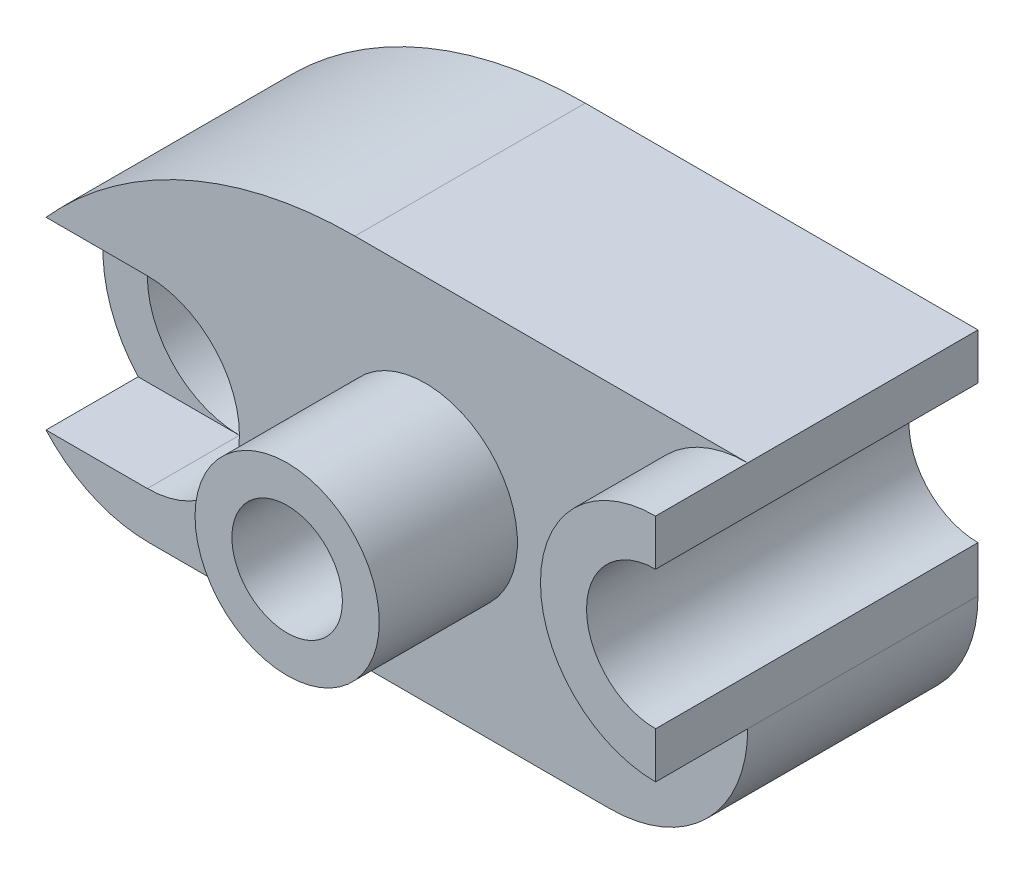
from build123d import *

# Parameters (mm, degrees)
SKETCH1_W           = 160
SKETCH1_H           = 80
BOSS_EXTRUDE1_DEPTH = 90
CUT_EXTRUDE1_DEPTH  = 90
CUT_EXTRUDE2_DEPTH  = 90
SKETCH4_W           = 10
SKETCH4_H           = 15
CUT_EXTRUDE3_DEPTH  = 215
CUT_EXTRUDE4_DEPTH  = 10
CUT_EXTRUDE6_DEPTH  = 263
SKETCH7_W           = 160
SKETCH7_H           = 80
CUT_EXTRUDE7_DEPTH  = 263
SKETCH8_R           = 20
BOSS_EXTRUDE2_DEPTH = 30
SKETCH9_R           = 11
CUT_EXTRUDE8_DEPTH  = 117
BOSS_EXTRUDE3_DEPTH = 20
CUT_EXTRUDE9_DEPTH  = 20
SKETCH12_R          = 20
CUT_EXTRUDE10_DEPTH = 40
SKETCH13_R          = 10
CUT_EXTRUDE11_DEPTH = 40
SKETCH14_R          = 12
CUT_EXTRUDE12_DEPTH = 114


with BuildPart() as part:
    # Sketch1 → Boss-Extrude1 (new body)
    with BuildSketch(Plane.XY):
        with Locations((80, 40)):
            Rectangle(SKETCH1_W, SKETCH1_H)
    extrude(amount=BOSS_EXTRUDE1_DEPTH)

    # Sketch2 → Cut-Extrude1 (cut)
    with BuildSketch(Plane.XY.offset(90)):
        with BuildLine():
            ThreePointArc((160, 70), (145, 55), (160, 40))
            Line((160, 40), (160, 70))
        make_face()
        with BuildLine():
            ThreePointArc((160, 30), (151.213203436, 8.786796564), (130, 0))
            Line((130, 0), (160, 0))
            Line((160, 0), (160, 30))
        make_face()
    extrude(amount=-CUT_EXTRUDE1_DEPTH, mode=Mode.SUBTRACT)

    # Sketch3 → Cut-Extrude2 (cut)
    with BuildSketch(Plane.XY.offset(90)):
        with BuildLine():
            Line((0, 30), (0, 0))
            Line((0, 0), (30, 0))
            ThreePointArc((30, 0), (8.786796564, 8.786796564), (0, 30))
        make_face()
    extrude(amount=-CUT_EXTRUDE2_DEPTH, mode=Mode.SUBTRACT)

    # Sketch4 → Cut-Extrude3 (cut)
    with BuildSketch(Plane.ZY):
        with Locations((5, 72.5)):
            Rectangle(SKETCH4_W, SKETCH4_H)
        with Locations((5, 7.5)):
            Rectangle(SKETCH4_W, SKETCH4_H)
    extrude(amount=-CUT_EXTRUDE3_DEPTH, mode=Mode.SUBTRACT)

    # Sketch5 → Cut-Extrude4 (cut)
    with BuildSketch(Plane(origin=(0, 0, 0), x_dir=(-1, 0, 0), z_dir=(0, 0, -1))):
        with BuildLine():
            ThreePointArc((-90, 15), (-115, 40), (-90, 65))
            Line((-90, 65), (-148.819660113, 65))
            ThreePointArc((-148.819660113, 65), (-146.306936062, 48.876275643), (-160, 40))
            Line((-160, 40), (-160, 30))
            ThreePointArc((-160, 30), (-158.977774789, 22.235428647), (-155.980762114, 15))
            Line((-155.980762114, 15), (-90, 15))
        make_face()
        with BuildLine():
            Line((0, 65), (-90, 65))
            ThreePointArc((-90, 65), (-72.32233047, 57.67766953), (-65, 40))
            ThreePointArc((-65, 40), (-72.32233047, 22.32233047), (-90, 15))
            Line((-90, 15), (-4.019237886, 15))
            ThreePointArc((-4.019237886, 15), (-1.022225211, 22.235428647), (0, 30))
            Line((0, 30), (0, 65))
        make_face()
    extrude(amount=-CUT_EXTRUDE4_DEPTH, mode=Mode.SUBTRACT)

    # Sketch6 → Cut-Extrude6 (cut)
    with BuildSketch(Plane.XY.offset(90)):
        with BuildLine():
            Line((0, 30), (0, 80))
            Line((0, 80), (74.72135955, 80))
            ThreePointArc((74.72135955, 80), (37.979013408, 72.158383626), (7.639320225, 50))
            ThreePointArc((7.639320225, 50), (1.974829231, 40.704662693), (0, 30))
        make_face()
    extrude(amount=-CUT_EXTRUDE6_DEPTH, mode=Mode.SUBTRACT)

    # Sketch7 → Cut-Extrude7 (cut)
    with BuildSketch(Plane.XY.offset(60)):
        with Locations((80, 40)):
            Rectangle(SKETCH7_W, SKETCH7_H)
    extrude(amount=CUT_EXTRUDE7_DEPTH, mode=Mode.SUBTRACT)

    # Sketch8 → Boss-Extrude2 (add)
    with BuildSketch(Plane.XY.offset(60)):
        with Locations((90, 40)):
            Circle(SKETCH8_R)
    extrude(amount=BOSS_EXTRUDE2_DEPTH)

    # Sketch9 → Cut-Extrude8 (cut)
    with BuildSketch(Plane.XY.offset(90)):
        with Locations((90, 40)):
            Circle(SKETCH9_R)
    extrude(amount=-CUT_EXTRUDE8_DEPTH, mode=Mode.SUBTRACT)

    # Sketch10 → Boss-Extrude3 (add)
    with BuildSketch(Plane.XY.offset(60)):
        with BuildLine():
            Line((160, 40), (160, 30))
            ThreePointArc((160, 30), (135, 55), (160, 80))
            Line((160, 80), (160, 70))
            ThreePointArc((160, 70), (145, 55), (160, 40))
        make_face()
    extrude(amount=BOSS_EXTRUDE3_DEPTH)

    # Sketch11 → Cut-Extrude9 (cut)
    with BuildSketch(Plane.XY.offset(60)):
        with BuildLine():
            ThreePointArc((29.639320225, 10), (9.639320225, 30), (29.639320225, 50))
            Line((29.639320225, 50), (7.639320225, 50))
            ThreePointArc((7.639320225, 50), (0, 30), (7.639320225, 10))
            Line((7.639320225, 10), (29.639320225, 10))
        make_face()
    extrude(amount=-CUT_EXTRUDE9_DEPTH, mode=Mode.SUBTRACT)

    # Sketch12 → Cut-Extrude10 (cut)
    with BuildSketch(Plane.XY.offset(60)):
        with Locations((29.639320225, 30)):
            Circle(SKETCH12_R)
    extrude(amount=-CUT_EXTRUDE10_DEPTH, mode=Mode.SUBTRACT)

    # Sketch13 → Cut-Extrude11 (cut)
    with BuildSketch(Plane.XY.offset(20)):
        with Locations((29.639320225, 30)):
            Circle(SKETCH13_R)
    extrude(amount=-CUT_EXTRUDE11_DEPTH, mode=Mode.SUBTRACT)

    # Sketch14 → Cut-Extrude12 (cut)
    with BuildSketch(Plane.XY.offset(90)):
        with Locations((90, 40)):
            Circle(SKETCH14_R)
    extrude(amount=-CUT_EXTRUDE12_DEPTH, mode=Mode.SUBTRACT)


solid = part.part
